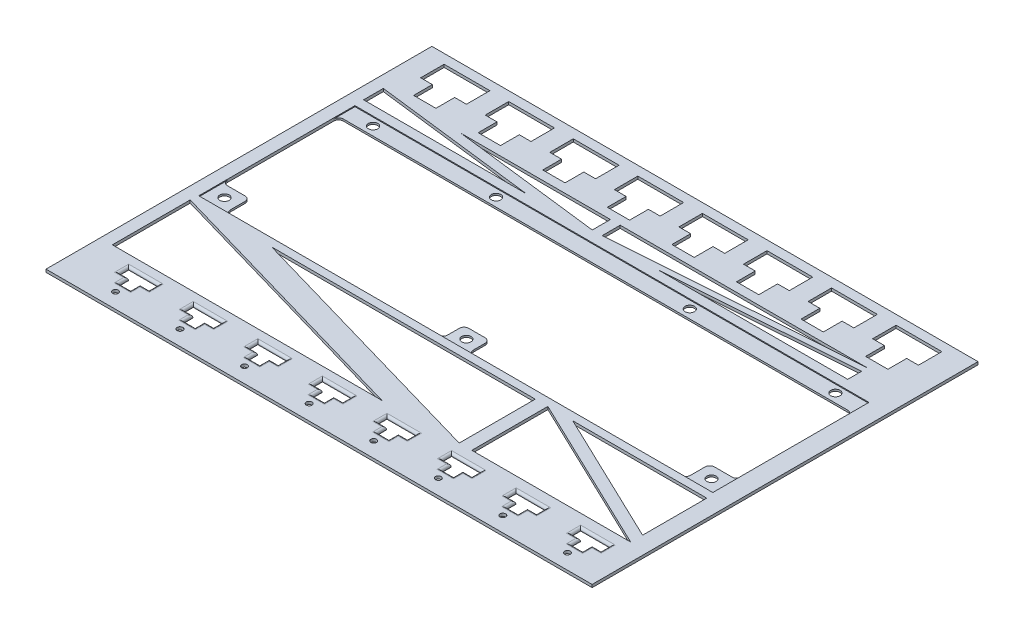
from build123d import *

# Parameters (mm, degrees)
SKETCH1_W              = 260
SKETCH1_H              = 186.9
BOSS_EXTRUDE1_DEPTH    = 1.2
SKETCH2_W              = 218.9
SKETCH2_H              = 66.5
CUT_EXTRUDE1_DEPTH     = 9
SKETCH4_W              = 218.9
SKETCH4_H              = 7
SKETCH4_W_2            = 11.5
SKETCH4_H_2            = 10.2
SKETCH4_W_3            = 11
SKETCH4_H_3            = 9
BOSS_EXTRUDE2_DEPTH    = 0.8
SKETCH3_R              = 2
CUT_EXTRUDE2_DEPTH     = 10
FILLET1_R              = 2
SKETCH10_W             = 19.5
SKETCH10_H             = 10
CUT_EXTRUDE4_DEPTH     = 1.2
SKETCH11_W             = 9.5
SKETCH11_H             = 8
CUT_EXTRUDE5_DEPTH     = 7
LPATTERN1_COUNT        = 8
LPATTERN1_PITCH        = 27.5
SKETCH14_R             = 1.2
CUT_EXTRUDE8_DEPTH     = 1.2
FILLET2_R              = 1
LPATTERN4_COUNT        = 8
LPATTERN4_PITCH        = 27.5
FILLET2_OF_LPATTERN4_R = 1
CUT_EXTRUDE9_DEPTH     = 10


with BuildPart() as part:
    # Sketch1 → Boss-Extrude1 (new body)
    with BuildSketch(Plane(origin=(0, 0, 0), x_dir=(1, 0, 0), z_dir=(0, 1, 0))):
        with Locations((115, 93.45)):
            Rectangle(SKETCH1_W, SKETCH1_H)
    extrude(amount=BOSS_EXTRUDE1_DEPTH)

    # Sketch2 → Cut-Extrude1 (cut)
    with BuildSketch(Plane(origin=(0, 0, 0), x_dir=(1, 0, 0), z_dir=(0, 1, 0))):
        with Locations((127.36, 115.4)):
            Rectangle(SKETCH2_W, SKETCH2_H)
    extrude(amount=CUT_EXTRUDE1_DEPTH, mode=Mode.SUBTRACT)

    # Sketch4 → Boss-Extrude2 (add)
    with BuildSketch(Plane(origin=(0, 0, 0), x_dir=(1, 0, 0), z_dir=(0, 1, 0))):
        with Locations((127.36, 145.15)):
            Rectangle(SKETCH4_W, SKETCH4_H)
        with Locations((231.06, 87.25)):
            Rectangle(SKETCH4_W_2, SKETCH4_H_2)
        with Locations((127.36, 86.65)):
            Rectangle(SKETCH4_W_3, SKETCH4_H_3)
        with Locations((23.66, 87.25)):
            Rectangle(SKETCH4_W_2, SKETCH4_H_2)
    extrude(amount=BOSS_EXTRUDE2_DEPTH)

    # Sketch3 → Cut-Extrude2 (cut)
    with BuildSketch(Plane(origin=(0, 1.2, 0), x_dir=(1, 0, 0), z_dir=(0, 1, 0))):
        with Locations((28.91, 145.35)):
            Circle(SKETCH3_R)
        with Locations((81.31, 145.35)):
            Circle(SKETCH3_R)
        with Locations((163.81, 145.35)):
            Circle(SKETCH3_R)
        with Locations((225.81, 145.35)):
            Circle(SKETCH3_R)
        with Locations((23.66, 87.35)):
            Circle(SKETCH3_R)
        with Locations((127.36, 86.65)):
            Circle(SKETCH3_R)
        with Locations((231.06, 87.35)):
            Circle(SKETCH3_R)
    extrude(amount=-CUT_EXTRUDE2_DEPTH, mode=Mode.SUBTRACT)

    # Fillet1
    fillet1_edges = [part.edges().sort_by_distance(p)[0] for p in [
        (17.91, 0.4, -141.65),
        (236.81, 0.4, -141.65),
        (236.81, 0.4, -92.35),
        (225.31, 0.4, -92.35),
        (225.31, 0.4, -82.15),
        (121.86, 0.4, -91.15),
        (121.86, 0.4, -82.15),
        (132.86, 0.4, -82.15),
        (132.86, 0.4, -91.15),
        (17.91, 0.4, -92.35),
        (29.41, 0.4, -82.15),
        (29.41, 0.4, -92.35),
    ]]
    fillet(fillet1_edges, radius=FILLET1_R)

    # Sketch10 → Cut-Extrude4 (cut)
    with BuildSketch(Plane(origin=(0, 1.2, 0), x_dir=(1, 0, 0), z_dir=(0, 1, 0))):
        with Locations((31.38, 177.9)):
            Rectangle(SKETCH10_W, SKETCH10_H)
    cut_extrude4 = extrude(amount=-CUT_EXTRUDE4_DEPTH, mode=Mode.SUBTRACT)

    # Sketch11 → Cut-Extrude5 (cut)
    with BuildSketch(Plane(origin=(0, 1.2, 0), x_dir=(1, 0, 0), z_dir=(0, 1, 0))):
        with Locations((31.38, 168.9)):
            Rectangle(SKETCH11_W, SKETCH11_H)
    cut_extrude5 = extrude(amount=-CUT_EXTRUDE5_DEPTH, mode=Mode.SUBTRACT)

    # LPattern1: Cut-Extrude4, Cut-Extrude5 ×8
    with Locations(*[(i * LPATTERN1_PITCH, 0, 0) for i in range(1, LPATTERN1_COUNT)]):
        add(cut_extrude4, mode=Mode.SUBTRACT)
        add(cut_extrude5, mode=Mode.SUBTRACT)

    # Sketch14 → Cut-Extrude8 (cut)
    with BuildSketch(Plane(origin=(0, 1.2, 0), x_dir=(1, 0, 0), z_dir=(0, 1, 0))):
        with Locations((35.54, 29)):
            Circle(SKETCH14_R)
        Polygon((29.19, 37), (33.04, 37), (33.04, 33), (38.04, 33), (38.04, 37), (41.89, 37), (41.89, 41), (29.19, 41), align=None)
    cut_extrude8 = extrude(amount=-CUT_EXTRUDE8_DEPTH, mode=Mode.SUBTRACT)

    # Fillet2
    fillet2_edges = [part.edges().sort_by_distance(p)[0] for p in [
        (29.19, 1.2, -39),
        (31.115, 1.2, -37),
        (33.04, 1.2, -35),
        (35.54, 1.2, -33),
        (38.04, 1.2, -35),
        (39.965, 1.2, -37),
        (41.89, 1.2, -39),
        (35.54, 1.2, -41),
    ]]
    fillet(fillet2_edges, radius=FILLET2_R)

    # LPattern4: Cut-Extrude8 ×8
    with Locations(*[(i * LPATTERN4_PITCH, 0, 0) for i in range(1, LPATTERN4_COUNT)]):
        add(cut_extrude8, mode=Mode.SUBTRACT)

    # Fillet2 of LPattern4
    fillet2_of_lpattern4_edges = [part.edges().sort_by_distance(p)[0] for p in [
        (56.69, 1.2, -39),
        (58.615, 1.2, -37),
        (60.54, 1.2, -35),
        (63.04, 1.2, -33),
        (65.54, 1.2, -35),
        (67.465, 1.2, -37),
        (69.39, 1.2, -39),
        (63.04, 1.2, -41),
        (84.19, 1.2, -39),
        (86.115, 1.2, -37),
        (88.04, 1.2, -35),
        (90.54, 1.2, -33),
        (93.04, 1.2, -35),
        (94.965, 1.2, -37),
        (96.89, 1.2, -39),
        (90.54, 1.2, -41),
        (111.69, 1.2, -39),
        (113.615, 1.2, -37),
        (115.54, 1.2, -35),
        (118.04, 1.2, -33),
        (120.54, 1.2, -35),
        (122.465, 1.2, -37),
        (124.39, 1.2, -39),
        (118.04, 1.2, -41),
        (139.19, 1.2, -39),
        (141.115, 1.2, -37),
        (143.04, 1.2, -35),
        (145.54, 1.2, -33),
        (148.04, 1.2, -35),
        (149.965, 1.2, -37),
        (151.89, 1.2, -39),
        (145.54, 1.2, -41),
        (166.69, 1.2, -39),
        (168.615, 1.2, -37),
        (170.54, 1.2, -35),
        (173.04, 1.2, -33),
        (175.54, 1.2, -35),
        (177.465, 1.2, -37),
        (179.39, 1.2, -39),
        (173.04, 1.2, -41),
        (194.19, 1.2, -39),
        (196.115, 1.2, -37),
        (198.04, 1.2, -35),
        (200.54, 1.2, -33),
        (203.04, 1.2, -35),
        (204.965, 1.2, -37),
        (206.89, 1.2, -39),
        (200.54, 1.2, -41),
        (221.69, 1.2, -39),
        (223.615, 1.2, -37),
        (225.54, 1.2, -35),
        (228.04, 1.2, -33),
        (230.54, 1.2, -35),
        (232.465, 1.2, -37),
        (234.39, 1.2, -39),
        (228.04, 1.2, -41),
    ]]
    fillet(fillet2_of_lpattern4_edges, radius=FILLET2_OF_LPATTERN4_R)

    # Sketch15 → Cut-Extrude9 (cut)
    with BuildSketch(Plane(origin=(0, 1.2, 0), x_dir=(1, 0, 0), z_dir=(0, 1, 0))):
        Polygon((-15, 186.9), (12.420995163, 186.9), (12.420995163, 22.553404287), (245, 22.553404287), (245, 0), (12.420995163, 0), (-15, 0), align=None)
        Polygon((17.595219871, 161.038310249), (17.595219871, 152.630195098), (86.929830959, 152.630195098), align=None)
        Polygon((50.580902385, 161.038310249), (114.310160465, 153.309948728), (114.310160465, 161.038310249), align=None)
        Polygon((118.492601678, 161.038310249), (118.492601678, 153.309948728), (223.788074487, 161.038310249), align=None)
        Polygon((143.199524659, 152.630195098), (223.788074487, 158.545145009), (223.788074487, 152.630195098), align=None)
        Polygon((17.595219871, 78.790773203), (17.595219871, 45.651161867), (132.457023327, 45.651161867), align=None)
        Polygon((52.262525415, 78.790773203), (164.557478203, 46.391742556), (164.557478203, 78.790773203), align=None)
        Polygon((169.922196339, 78.790773203), (169.922196339, 46.391742556), (237.593238588, 46.391742556), align=None)
        Polygon((180.521275245, 78.790773203), (237.593238588, 51.466289525), (237.593238588, 78.790773203), align=None)
    extrude(amount=-CUT_EXTRUDE9_DEPTH, mode=Mode.SUBTRACT)


solid = part.part
